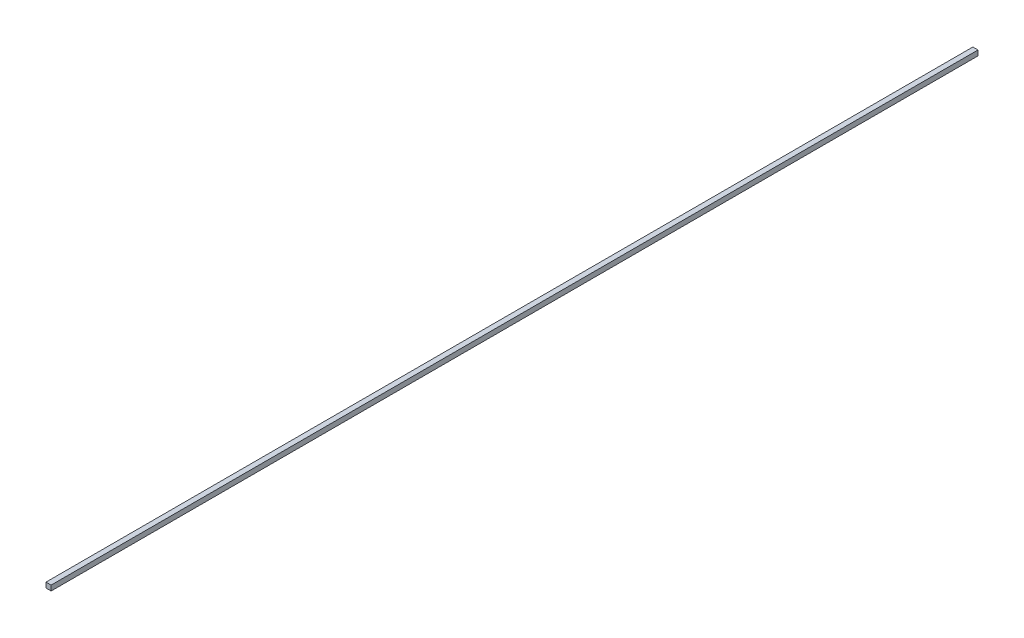
from build123d import *

# Parameters (mm, degrees)
SKETCH1_W           = 10
SKETCH1_H           = 10
BOSS_EXTRUDE1_DEPTH = 1800


with BuildPart() as part:
    # Sketch1 → Boss-Extrude1 (new body)
    with BuildSketch(Plane.XY):
        Rectangle(SKETCH1_W, SKETCH1_H)
    extrude(amount=BOSS_EXTRUDE1_DEPTH)


solid = part.part
